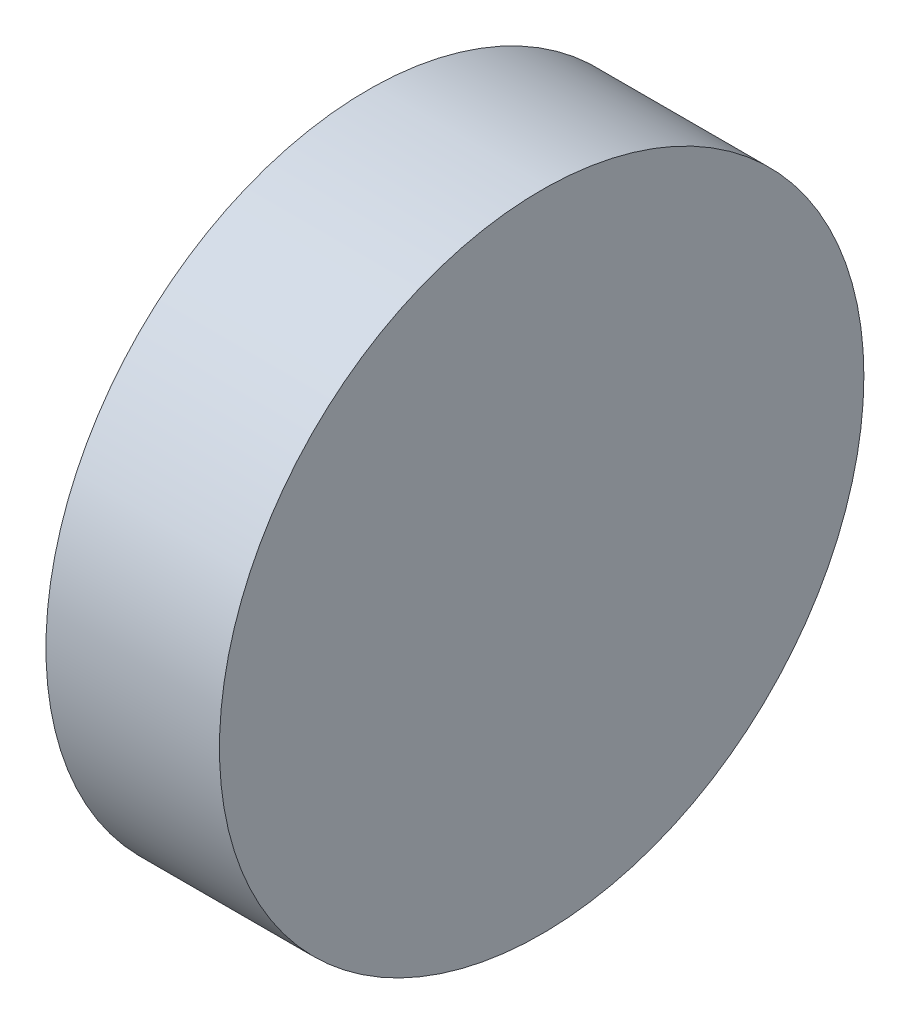
from build123d import *

# Parameters (mm, degrees)
SKETCH3_R           = 165.1
BOSS_EXTRUDE3_DEPTH = 88.9


with BuildPart() as part:
    # Sketch3 → Boss-Extrude3 (new body)
    with BuildSketch(Plane(origin=(0, 0, 0), x_dir=(0, 0, -1), z_dir=(1, 0, 0))):
        Circle(SKETCH3_R)
    extrude(amount=BOSS_EXTRUDE3_DEPTH)


solid = part.part
